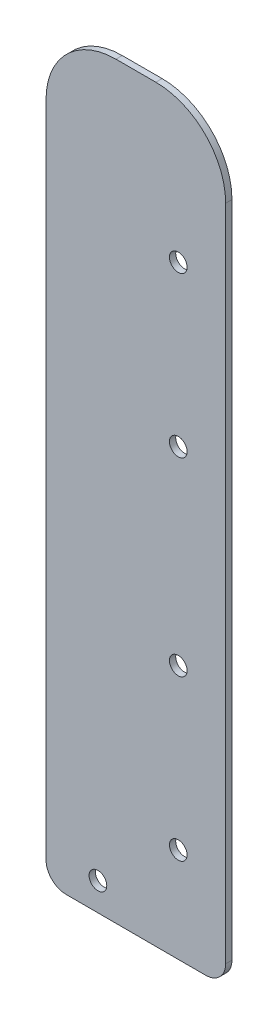
from build123d import *

# Parameters (mm, degrees)
SKETCH1_R           = 2.2479
BOSS_EXTRUDE2_DEPTH = 1.6002


with BuildPart() as part:
    # Sketch1 → Boss-Extrude2 (new body)
    with BuildSketch(Plane.XY):
        with BuildLine():
            Line((45.72, 5.08), (45.72, 172.72))
            ThreePointArc((45.72, 172.72), (40.512358569, 185.292358569), (27.94, 190.5))
            Line((27.94, 190.5), (17.78, 190.5))
            ThreePointArc((17.78, 190.5), (5.207641431, 185.292358569), (0, 172.72))
            Line((0, 172.72), (0, 5.08))
            ThreePointArc((0, 5.08), (1.503493452, 1.526611814), (5.070014314, 0.054542149))
            Line((5.070014314, 0.054542149), (33.655, 0))
            Line((33.655, 0), (40.64, 0))
            ThreePointArc((40.64, 0), (44.232102448, 1.487897552), (45.72, 5.08))
        make_face()
        with Locations((33.655, 24.13)):
            Circle(SKETCH1_R, mode=Mode.SUBTRACT)
        with Locations((33.655, 64.77)):
            Circle(SKETCH1_R, mode=Mode.SUBTRACT)
        with Locations((33.655, 113.03)):
            Circle(SKETCH1_R, mode=Mode.SUBTRACT)
        with Locations((33.655, 153.67)):
            Circle(SKETCH1_R, mode=Mode.SUBTRACT)
        with Locations((13.208, 7.15102725)):
            Circle(SKETCH1_R, mode=Mode.SUBTRACT)
    extrude(amount=BOSS_EXTRUDE2_DEPTH)


solid = part.part
